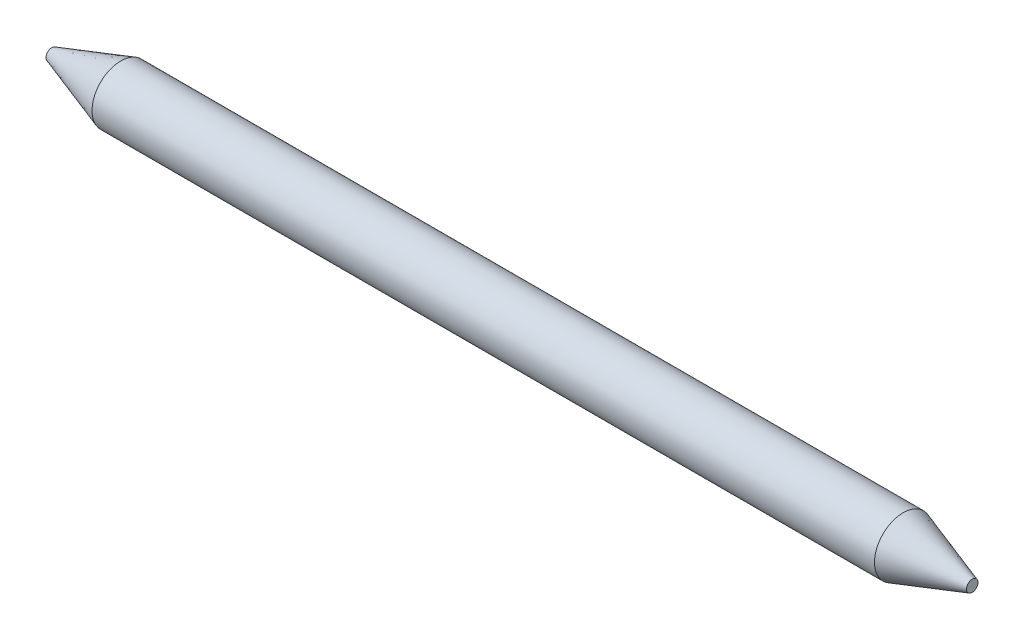
from build123d import *

# Parameters (mm, degrees)
SKETCH1_R          = 1.5875
MAIN_DEPTH         = 25.4
ENDS_CHAMFER_SIZE  = 3.81
ENDS_CHAMFER_SIZE2 = 1.27


with BuildPart() as part:
    # Sketch1 → main (new body, symmetric)
    with BuildSketch(Plane(origin=(0, 0, 0), x_dir=(0, 0, -1), z_dir=(1, 0, 0))):
        Circle(SKETCH1_R)
    extrude(amount=MAIN_DEPTH, both=True)

    # ends chamfer
    ends_chamfer_edges = [part.edges().sort_by_distance(p)[0] for p in [
        (-25.4, 0, 1.5875),
        (25.4, 0, 1.5875),
    ]]
    ends_chamfer_side = [part.faces().sort_by_distance(p)[0] for p in [
        (0, 0, 1.5875),
    ]]
    chamfer(ends_chamfer_edges, length=ENDS_CHAMFER_SIZE, length2=ENDS_CHAMFER_SIZE2, reference=ends_chamfer_side[0])


solid = part.part
